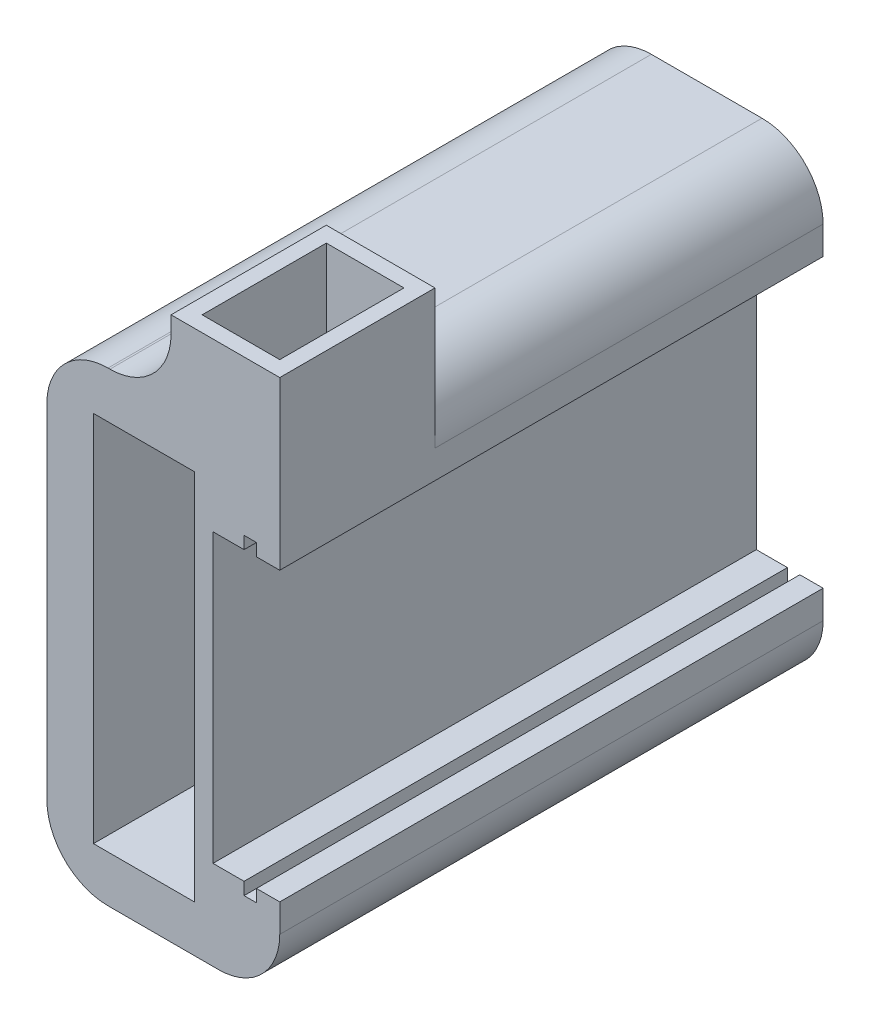
from build123d import *

# Parameters (mm, degrees)
SKETCH1_W           = 38.1
SKETCH1_H           = 88.9
BOSS_EXTRUDE1_DEPTH = 76.2
SKETCH2_W           = 16.51
SKETCH2_H           = 60.96
CUT_EXTRUDE1_DEPTH  = 76.2
SKETCH3_W           = 5.08
SKETCH3_H           = 46.99
SKETCH3_W_2         = 2.032
SKETCH3_W_3         = 3.81
SKETCH3_H_2         = 2.032
CUT_EXTRUDE2_DEPTH  = 89.9
SKETCH5_W           = 7.62
SKETCH5_H           = 12.7
CUT_EXTRUDE3_DEPTH  = 14.605
SKETCH6_W           = 17.78
SKETCH6_H           = 25.4
SKETCH6_W_2         = 12.7
SKETCH6_H_2         = 20.32
BOSS_EXTRUDE2_DEPTH = 12.7
FILLET2_R           = 10
SKETCH7_R           = 2.7305
CUT_EXTRUDE4_DEPTH  = 12.7


with BuildPart() as part:
    # Sketch1 → Boss-Extrude1 (new body)
    with BuildSketch(Plane(origin=(0, 0, 0), x_dir=(1, 0, 0), z_dir=(0, 1, 0))):
        with Locations((19.05, 44.45)):
            Rectangle(SKETCH1_W, SKETCH1_H)
    extrude(amount=BOSS_EXTRUDE1_DEPTH)

    # Sketch2 → Cut-Extrude1 (cut)
    with BuildSketch(Plane.XY):
        with Locations((15.875, 38.1)):
            Rectangle(SKETCH2_W, SKETCH2_H)
    extrude(amount=-CUT_EXTRUDE1_DEPTH, mode=Mode.SUBTRACT)

    # Sketch3 → Cut-Extrude2 (cut, through all)
    with BuildSketch(Plane.XY):
        with Locations((29.718, 38.1)):
            Rectangle(SKETCH3_W, SKETCH3_H)
        with Locations((33.274, 38.1)):
            Rectangle(SKETCH3_W_2, SKETCH3_H)
        with Locations((36.195, 38.1)):
            Rectangle(SKETCH3_W_3, SKETCH3_H)
        with Locations((33.274, 62.611)):
            Rectangle(SKETCH3_W_2, SKETCH3_H_2)
        with Locations((33.274, 13.589)):
            Rectangle(SKETCH3_W_2, SKETCH3_H_2)
    extrude(amount=-CUT_EXTRUDE2_DEPTH, mode=Mode.SUBTRACT)

    # Sketch5 → Cut-Extrude3 (cut)
    with BuildSketch(Plane(origin=(0, 76.2, 0), x_dir=(1, 0, 0), z_dir=(0, 1, 0))):
        with Locations((29.21, 8.89)):
            Rectangle(SKETCH5_W, SKETCH5_H)
    extrude(amount=-CUT_EXTRUDE3_DEPTH, mode=Mode.SUBTRACT)

    # Sketch6 → Boss-Extrude2 (add)
    with BuildSketch(Plane(origin=(0, 76.2, 0), x_dir=(1, 0, 0), z_dir=(0, 1, 0))):
        with Locations((29.21, 12.7)):
            Rectangle(SKETCH6_W, SKETCH6_H)
        with Locations((29.21, 12.7)):
            Rectangle(SKETCH6_W_2, SKETCH6_H_2, mode=Mode.SUBTRACT)
    extrude(amount=BOSS_EXTRUDE2_DEPTH)

    # Fillet2
    fillet2_edges = [part.edges().sort_by_distance(p)[0] for p in [
        (20.32, 76.2, -12.7),
        (0, 76.2, -44.45),
        (38.1, 0, -44.45),
        (0, 0, -44.45),
        (38.1, 76.2, -57.15),
    ]]
    fillet(fillet2_edges, radius=FILLET2_R)

    # Sketch7 → Cut-Extrude4 (cut)
    with BuildSketch(Plane(origin=(0, 0, -88.9), x_dir=(-1, 0, 0), z_dir=(0, 0, -1))):
        with Locations((-13.589, 63.5)):
            Circle(SKETCH7_R)
        with Locations((-13.589, 12.7)):
            Circle(SKETCH7_R)
    extrude(amount=-CUT_EXTRUDE4_DEPTH, mode=Mode.SUBTRACT)


solid = part.part
